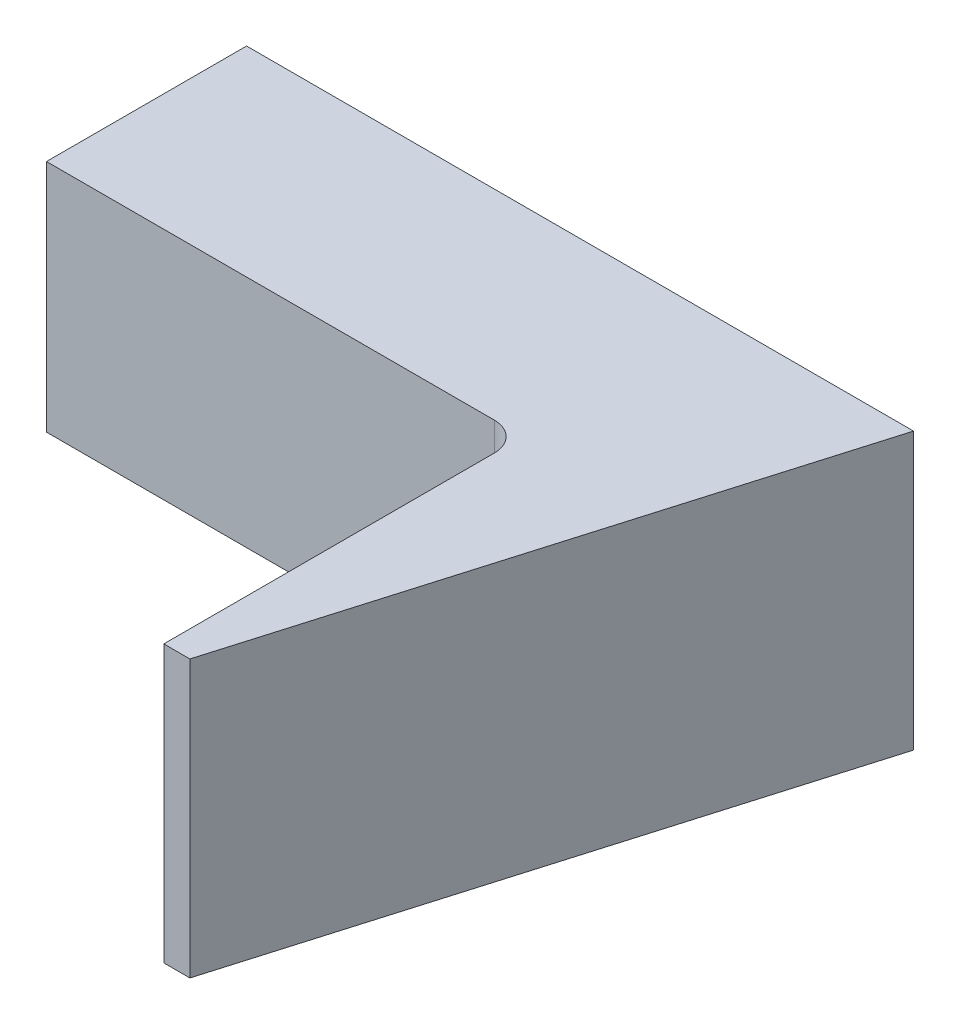
from build123d import *

# Parameters (mm, degrees)
EXTRUDE1_DEPTH          = 5.334
SKETCH20_W              = 5.08
SKETCH20_H              = 5.715
EXTRUDE3_DEPTH          = 12.7
SKETCH22_W              = 0.889
SKETCH22_H              = 2.54
EXTRUDE5_DEPTH          = 5.334
SKETCH23_W              = 5.08
SKETCH23_H              = 1.5875
EXTRUDE6_DEPTH          = 3.683
FILLET5_R               = 1.6002
FILLET6_R               = 0.8382
FILLET2_R               = 0.762
CUT_EXTRUDE4_DEPTH      = 1
CUT_EXTRUDE4_DEPTH_BACK = 11.922
CUT_EXTRUDE5_DEPTH      = 1
CUT_EXTRUDE5_DEPTH_BACK = 11.922
CUT_EXTRUDE7_DEPTH      = 1
CUT_EXTRUDE7_DEPTH_BACK = 11.922
CUT_EXTRUDE8_DEPTH      = 1
CUT_EXTRUDE8_DEPTH_BACK = 18.78
BOSS_EXTRUDE1_DEPTH     = 7.366


with BuildPart() as part:
    # Sketch2 → Extrude1 (new body)
    with BuildSketch(Plane.XY):
        Polygon((-5.08, 0), (-5.08, -1.524), (0, -1.524), (0, 0), (0, 9.398), (-25.4, 9.398), (-25.4, 0), align=None)
    extrude(amount=EXTRUDE1_DEPTH)

    # Sketch20 → Extrude3 (add)
    with BuildSketch(Plane.XY.offset(5.334)):
        with Locations((-2.54, 6.5405)):
            Rectangle(SKETCH20_W, SKETCH20_H)
    extrude(amount=EXTRUDE3_DEPTH)

    # Sketch22 → Extrude5 (add)
    with BuildSketch(Plane.XY.offset(5.334)):
        with Locations((-25.8445, 8.128)):
            Rectangle(SKETCH22_W, SKETCH22_H)
    extrude(amount=-EXTRUDE5_DEPTH)

    # Sketch23 → Extrude6 (add)
    with BuildSketch(Plane.XZ.offset(-3.683)):
        with Locations((-2.54, 17.24025)):
            Rectangle(SKETCH23_W, SKETCH23_H)
    extrude(amount=EXTRUDE6_DEPTH)

    # Fillet5
    fillet5_edges = [part.edges().sort_by_distance(p)[0] for p in [
        (-26.289, 8.128, 5.334),
    ]]
    fillet(fillet5_edges, radius=FILLET5_R)

    # Fillet6
    fillet6_edges = [part.edges().sort_by_distance(p)[0] for p in [
        (-5.08, 1.8415, 16.4465),
    ]]
    fillet(fillet6_edges, radius=FILLET6_R)

    # Fillet2
    fillet2_edges = [part.edges().sort_by_distance(p)[0] for p in [
        (-5.08, 6.5405, 5.334),
        (0, 4.699, 18.034),
        (-5.08, 4.699, 18.034),
        (0, 1.0795, 5.334),
    ]]
    fillet(fillet2_edges, radius=FILLET2_R)

    # Sketch26 → Cut-Extrude4 (cut, two sides)
    with BuildSketch(Plane(origin=(0, 9.398, 0), x_dir=(1, 0, 0), z_dir=(0, 1, 0))) as cut_extrude4_sk:
        Polygon((20.812608211, 70.762867918), (0, 0), (-5.08, -17.272), (-25.892608211, -88.034867918), (115.633127624, -129.66008434), (162.338344046, 29.137651496), align=None)
    extrude(amount=CUT_EXTRUDE4_DEPTH, mode=Mode.SUBTRACT)
    extrude(cut_extrude4_sk.sketch, amount=-CUT_EXTRUDE4_DEPTH_BACK, mode=Mode.SUBTRACT)

    # Sketch27 → Cut-Extrude5 (cut, two sides)
    with BuildSketch(Plane(origin=(0, 9.398, 0), x_dir=(1, 0, 0), z_dir=(0, 1, 0))) as cut_extrude5_sk:
        Polygon((-68.071537779, -14.906771648), (-5.08, -14.906771648), (-4.384344602, -14.906771648), (58.607193177, -14.906771648), (58.607193177, -140.889847207), (-68.071537779, -140.889847207), align=None)
    extrude(amount=CUT_EXTRUDE5_DEPTH, mode=Mode.SUBTRACT)
    extrude(cut_extrude5_sk.sketch, amount=-CUT_EXTRUDE5_DEPTH_BACK, mode=Mode.SUBTRACT)

    # Sketch28 → Cut-Extrude7 (cut, two sides)
    with BuildSketch(Plane(origin=(0, 9.398, 0), x_dir=(1, 0, 0), z_dir=(0, 1, 0))) as cut_extrude7_sk:
        Polygon((-17.78, 56.40432053), (-17.78, 0), (-17.78, -5.334), (-17.78, -61.73832053), (-130.588641061, -61.73832053), (-130.588641061, 56.40432053), align=None)
    extrude(amount=CUT_EXTRUDE7_DEPTH, mode=Mode.SUBTRACT)
    extrude(cut_extrude7_sk.sketch, amount=-CUT_EXTRUDE7_DEPTH_BACK, mode=Mode.SUBTRACT)

    # Sketch29 → Cut-Extrude8 (cut, two sides)
    with BuildSketch(Plane.ZY.offset(17.78)) as cut_extrude8_sk:
        Polygon((-42.326728478, 3.1496), (0, 3.1496), (5.334, 3.1496), (47.660728478, 3.1496), (47.660728478, -81.503856957), (-42.326728478, -81.503856957), align=None)
    extrude(amount=CUT_EXTRUDE8_DEPTH, mode=Mode.SUBTRACT)
    extrude(cut_extrude8_sk.sketch, amount=-CUT_EXTRUDE8_DEPTH_BACK, mode=Mode.SUBTRACT)

    # Sketch30 → Boss-Extrude1 (add)
    with BuildSketch(Plane(origin=(0, 9.398, 0), x_dir=(1, 0, 0), z_dir=(0, 1, 0))):
        Polygon((-5.08, -14.906771648), (-5.08, 0), (0, 0), (-4.384344602, -14.906771648), align=None)
    extrude(amount=-BOSS_EXTRUDE1_DEPTH)


solid = part.part
